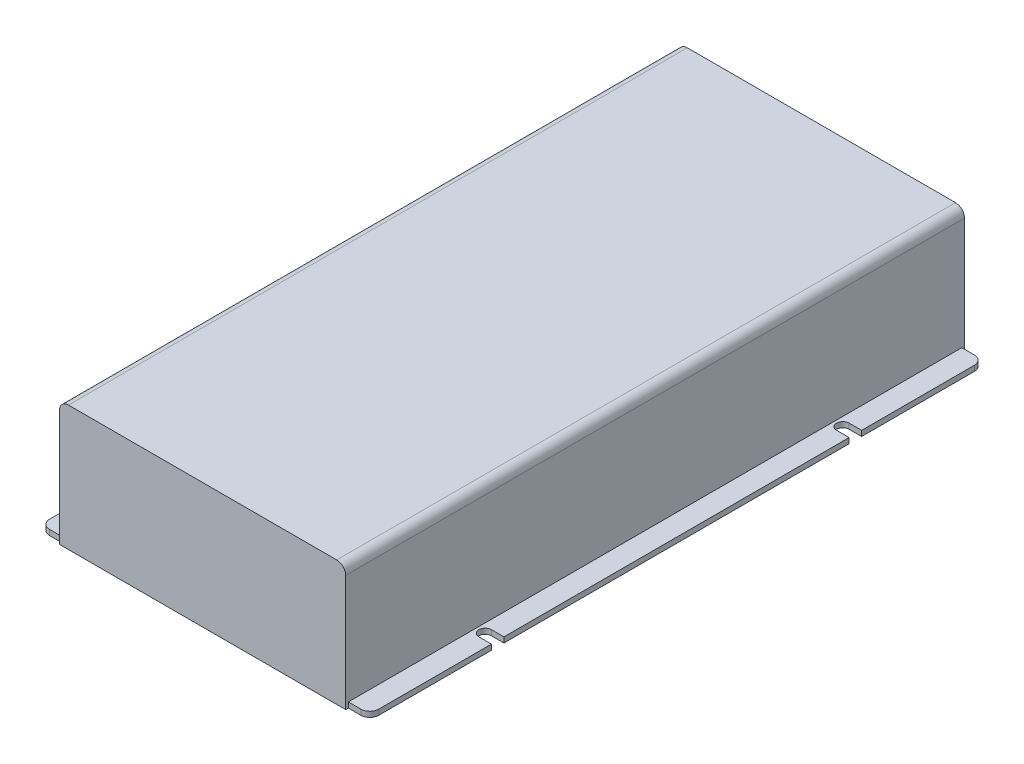
from build123d import *

# Parameters (mm, degrees)
CROQUIS1_W              = 160
CROQUIS1_H              = 70
SALIENTE_EXTRUIR1_DEPTH = 173
CROQUIS2_W              = 12
CROQUIS2_H              = 343
SALIENTE_EXTRUIR2_DEPTH = 3
CORTAR_EXTRUIR1_DEPTH   = 4
REDONDEO1_R             = 5


with BuildPart() as part:
    # Croquis1 → Saliente-Extruir1 (new body, symmetric)
    with BuildSketch(Plane.XY):
        with Locations((0, 35)):
            Rectangle(CROQUIS1_W, CROQUIS1_H)
    extrude(amount=SALIENTE_EXTRUIR1_DEPTH, both=True)

    # Croquis2 → Saliente-Extruir2 (add)
    with BuildSketch(Plane.XZ):
        with Locations((86, 0)):
            Rectangle(CROQUIS2_W, CROQUIS2_H)
    extrude(amount=-SALIENTE_EXTRUIR2_DEPTH)

    # Croquis3 → Cortar-Extruir1 (cut, through all)
    with BuildSketch(Plane(origin=(0, 3, 0), x_dir=(1, 0, 0), z_dir=(0, 1, 0))):
        with BuildLine():
            Line((85, -103.5), (92, -103.5))
            Line((92, -103.5), (92, -96.5))
            Line((92, -96.5), (85, -96.5))
            ThreePointArc((85, -96.5), (81.5, -100), (85, -103.5))
        make_face()
    cortar_extruir1 = extrude(amount=-CORTAR_EXTRUIR1_DEPTH, mode=Mode.SUBTRACT)

    # Simetría1: Cortar-Extruir1 across plane
    add(cortar_extruir1.mirror(Plane.XY), mode=Mode.SUBTRACT)

    # Simetría5: part across plane


with BuildPart() as part_1:
    add(part.part)
    add(part.part.mirror(Plane(origin=(0, 0, 0), x_dir=(0, 0, 1), z_dir=(1, 0, 0))))

    # Redondeo1
    redondeo1_edges = [part_1.edges().sort_by_distance(p)[0] for p in [
        (92, 1.5, 171.5),
        (92, 1.5, -171.5),
        (-92, 1.5, -171.5),
        (-92, 1.5, 171.5),
        (-80, 70, 0),
        (80, 70, 0),
    ]]
    fillet(redondeo1_edges, radius=REDONDEO1_R)


solid = part_1.part
